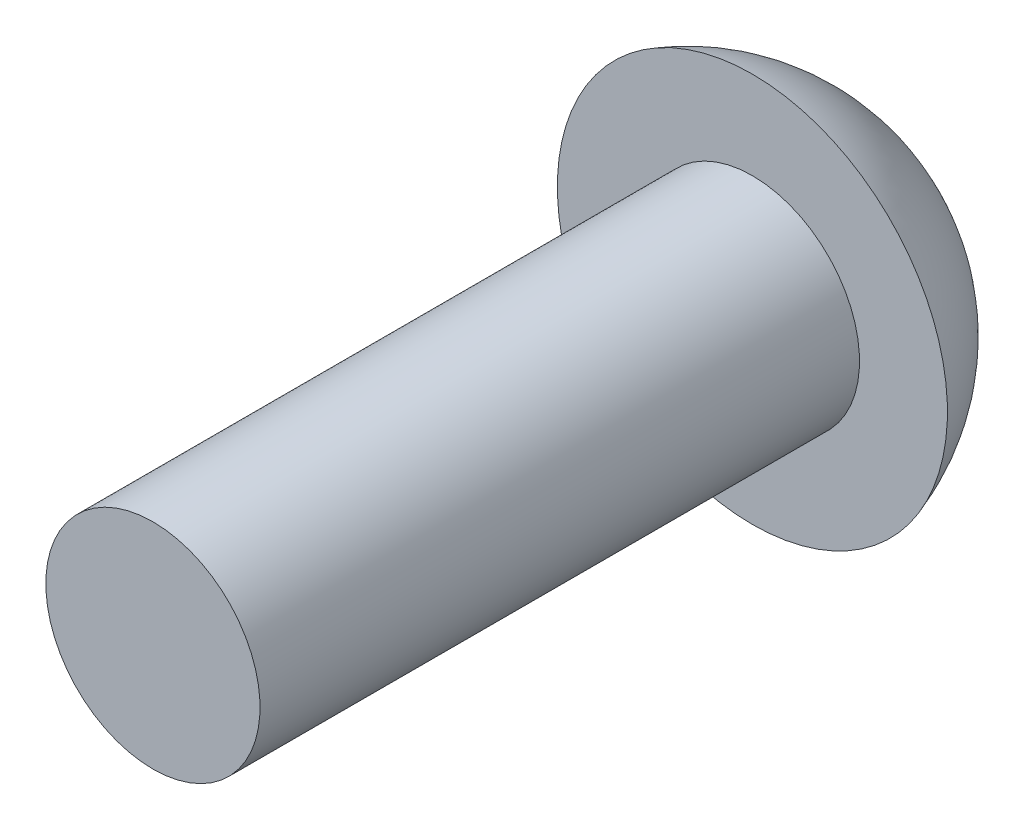
from build123d import *


with BuildPart() as part:
    # Sketch2 → Revolve1 (revolve)
    with BuildSketch(Plane(origin=(0, 0, 0), x_dir=(0, 0, -1), z_dir=(1, 0, 0))):
        with BuildLine():
            Line((0, 0), (0, 1.7018))
            Line((0, 1.7018), (9.525, 1.7018))
            Line((9.525, 1.7018), (9.525, 3.0988))
            ThreePointArc((9.525, 3.0988), (11.143092498, 1.910410982), (11.7602, 0))
            Line((11.7602, 0), (0, 0))
        make_face()
    revolve(axis=Axis((0, 0, 0), (0, 0, -1)))


solid = part.part
